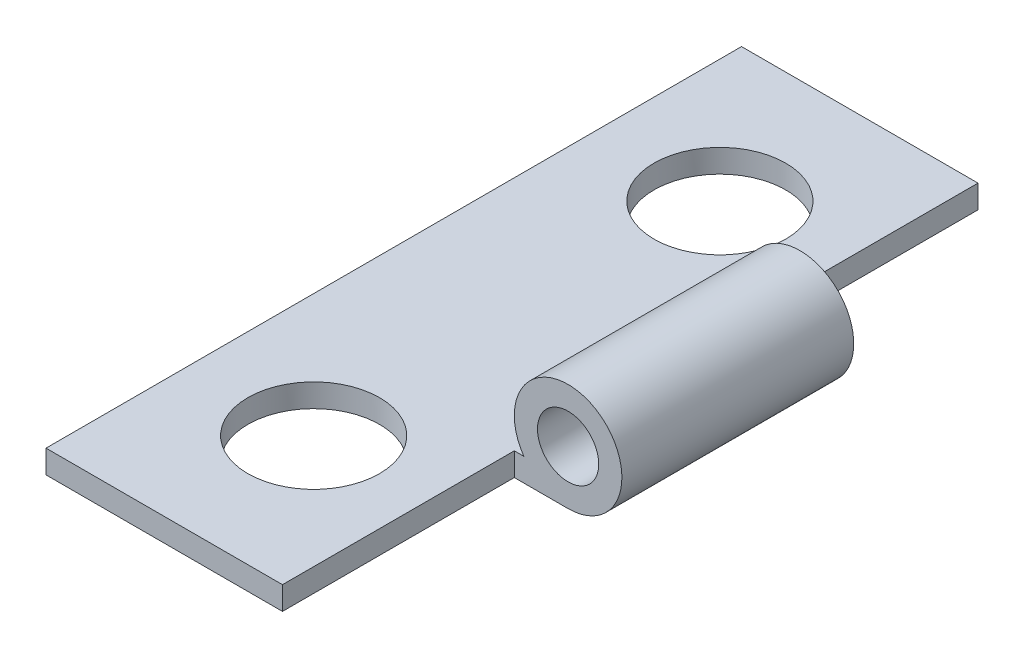
from build123d import *

# Parameters (mm, degrees)
SKETCH1_R           = 0.8382
BOSS_EXTRUDE1_DEPTH = 19.05
CUT_EXTRUDE1_START  = 76.2
SKETCH2_R           = 1.8034
SKETCH2_W           = 2.9464
SKETCH2_H           = 6.35
CUT_EXTRUDE1_DEPTH  = 127


with BuildPart() as part:
    # Sketch1 → Boss-Extrude1 (new body)
    with BuildSketch(Plane.XY):
        with BuildLine():
            Line((-11.0348776, 1.636724806), (-11.0348776, 2.271724806))
            Line((-11.0348776, 2.271724806), (-4.296180386, 2.271724806))
            ThreePointArc((-4.296180386, 2.271724806), (-2.400761669, 4.41475324), (-3.0846776, 1.636724806))
            Line((-3.0846776, 1.636724806), (-11.0348776, 1.636724806))
        make_face()
        with Locations((-3.0846776, 3.109924806)):
            Circle(SKETCH1_R, mode=Mode.SUBTRACT)
    extrude(amount=BOSS_EXTRUDE1_DEPTH)

    # Sketch2 → Cut-Extrude1 (cut)
    with BuildSketch(Plane(origin=(0, 2.271724806, 0), x_dir=(1, 0, 0), z_dir=(0, 1, 0)).offset(CUT_EXTRUDE1_START)):
        with Locations((-7.665528993, -3.9624)):
            Circle(SKETCH2_R)
        with Locations((-7.665528993, -15.0876)):
            Circle(SKETCH2_R)
        with Locations((-3.0846776, -3.175)):
            Rectangle(SKETCH2_W, SKETCH2_H)
        with Locations((-3.0846776, -15.875)):
            Rectangle(SKETCH2_W, SKETCH2_H)
    extrude(amount=-CUT_EXTRUDE1_DEPTH, mode=Mode.SUBTRACT)


solid = part.part
